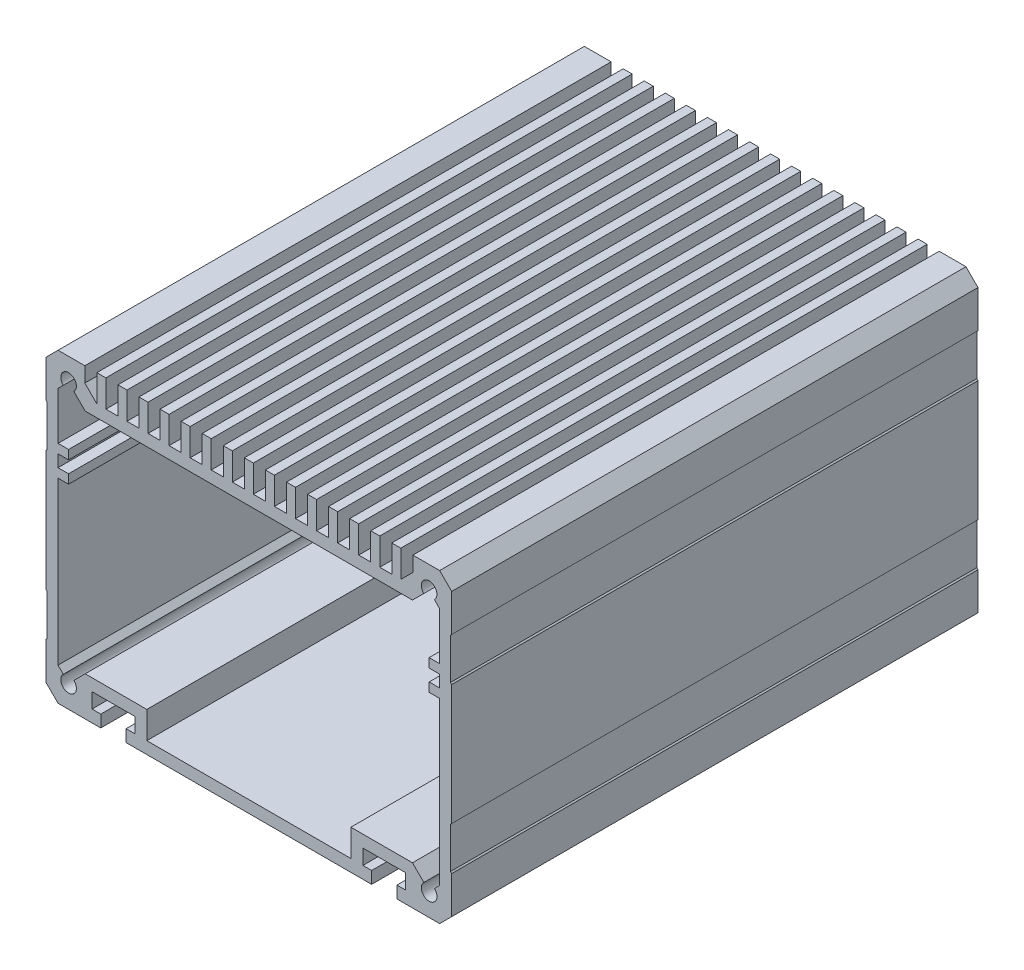
from build123d import *

# Parameters (mm, degrees)
BOSS_EXTRUDE1_DEPTH = 87.4395


with BuildPart() as part:
    # Sketch1 → Boss-Extrude1 (new body)
    with BuildSketch(Plane.XY.offset(12.5605)):
        Polygon((-54.188249545, 1.80757214), (-54.188249545, -0.19242786), (-13.388249545, -0.19242786), (-13.388249545, 1.80757214), (-14.838249545, 1.80757214), (-14.838249545, 4.30757214), (-7.738249545, 4.30757214), (-7.738249545, 1.80757214), (-9.188249545, 1.80757214), (-9.188249545, -0.19242786), (-2.088249216, -0.19242786), (-0.088249545, 1.807571812), (-0.088249545, 8.007572024), (-0.288249545, 8.207572024), (-0.288249545, 15.00757214), (-0.088249545, 15.20757214), (-0.088249545, 35.20757214), (-0.288249545, 35.40757214), (-0.288249545, 42.207572024), (-0.088249545, 42.407572024), (-0.088249545, 48.607572237), (-2.088249448, 50.60757214), (-6.538249545, 50.60757214), (-6.538249545, 48.10757214), (-8.538249545, 46.10757214), (-8.538249545, 50.60757214), (-10.038249545, 50.60757214), (-10.038249545, 46.10757214), (-12.038249545, 46.10757214), (-12.038249545, 50.60757214), (-13.538249545, 50.60757214), (-13.538249545, 46.10757214), (-15.538249545, 46.10757214), (-15.538249545, 50.60757214), (-17.038249545, 50.60757214), (-17.038249545, 46.10757214), (-19.038249545, 46.10757214), (-19.038249545, 50.60757214), (-20.538249545, 50.60757214), (-20.538249545, 46.10757214), (-22.538249545, 46.10757214), (-22.538249545, 50.60757214), (-24.038249545, 50.60757214), (-24.038249545, 46.10757214), (-26.038249545, 46.10757214), (-26.038249545, 50.60757214), (-27.538249545, 50.60757214), (-27.538249545, 46.10757214), (-29.538249545, 46.10757214), (-29.538249545, 50.60757214), (-31.038249545, 50.60757214), (-31.038249545, 46.10757214), (-33.038249545, 46.10757214), (-33.038249545, 50.60757214), (-34.538249545, 50.60757214), (-34.538249545, 46.10757214), (-36.538249545, 46.10757214), (-36.538249545, 50.60757214), (-38.038249545, 50.60757214), (-38.038249545, 46.10757214), (-40.038249545, 46.10757214), (-40.038249545, 50.60757214), (-41.538249545, 50.60757214), (-41.538249545, 46.10757214), (-43.538249545, 46.10757214), (-43.538249545, 50.60757214), (-45.038249545, 50.60757214), (-45.038249545, 46.10757214), (-47.038249545, 46.10757214), (-47.038249545, 50.60757214), (-48.538249545, 50.60757214), (-48.538249545, 46.10757214), (-50.538249545, 46.10757214), (-50.538249545, 50.60757214), (-52.038249545, 50.60757214), (-52.038249545, 46.10757214), (-54.038249545, 46.10757214), (-54.038249545, 50.60757214), (-55.538249545, 50.60757214), (-55.538249545, 46.10757214), (-57.538249545, 46.10757214), (-57.538249545, 50.60757214), (-59.038249545, 50.60757214), (-59.038249545, 46.10757214), (-61.038249545, 48.10757214), (-61.038249545, 50.60757214), (-65.488249642, 50.60757214), (-67.488249545, 48.607572237), (-67.488249545, 42.407572024), (-67.288249545, 42.207572024), (-67.288249545, 35.40757214), (-67.488249545, 35.20757214), (-67.488249545, 15.20757214), (-67.288249545, 15.00757214), (-67.288249545, 8.207572024), (-67.488249545, 8.007572024), (-67.488249545, 1.807571812), (-65.488249874, -0.19242786), (-58.388249545, -0.19242786), (-58.388249545, 1.80757214), (-59.838249545, 1.80757214), (-59.838249545, 4.30757214), (-52.738249545, 4.30757214), (-52.738249545, 1.80757214), align=None)
        with BuildLine():
            Line((-2.088249545, 32.20757214), (-2.088249545, 5.294016009))
            Line((-2.088249545, 5.294016009), (-2.963249358, 4.419016196))
            ThreePointArc((-2.963249358, 4.419016196), (-3.838249708, 2.15757214), (-4.713249491, 4.419016416))
            Line((-4.713249491, 4.419016416), (-6.601805216, 6.30757214))
            Line((-6.601805216, 6.30757214), (-16.838249545, 6.30757214))
            Line((-16.838249545, 6.30757214), (-16.838249545, 1.807572024))
            Line((-16.838249545, 1.807572024), (-50.738249545, 1.807572024))
            Line((-50.738249545, 1.807572024), (-50.738249545, 6.30757214))
            Line((-50.738249545, 6.30757214), (-60.974693874, 6.30757214))
            Line((-60.974693874, 6.30757214), (-62.863249599, 4.419016416))
            ThreePointArc((-62.863249599, 4.419016416), (-63.738249382, 2.15757214), (-64.613249732, 4.419016196))
            Line((-64.613249732, 4.419016196), (-65.488249545, 5.294016009))
            Line((-65.488249545, 5.294016009), (-65.488249545, 32.20757214))
            Line((-65.488249545, 32.20757214), (-63.738249545, 32.20757214))
            Line((-63.738249545, 32.20757214), (-63.738249545, 33.70757214))
            Line((-63.738249545, 33.70757214), (-65.488249545, 33.70757214))
            Line((-65.488249545, 33.70757214), (-65.488249545, 35.70757214))
            Line((-65.488249545, 35.70757214), (-63.738249545, 35.70757214))
            Line((-63.738249545, 35.70757214), (-63.738249545, 37.20757214))
            Line((-63.738249545, 37.20757214), (-65.488249545, 37.20757214))
            Line((-65.488249545, 37.20757214), (-65.488249545, 45.121128024))
            Line((-65.488249545, 45.121128024), (-64.613249603, 45.996127967))
            ThreePointArc((-64.613249603, 45.996127967), (-63.738249551, 48.25757214), (-62.863249479, 45.996127974))
            Line((-62.863249479, 45.996127974), (-60.974693645, 44.10757214))
            Line((-60.974693645, 44.10757214), (-6.601805445, 44.10757214))
            Line((-6.601805445, 44.10757214), (-4.713249611, 45.996127974))
            ThreePointArc((-4.713249611, 45.996127974), (-3.838249539, 48.25757214), (-2.963249487, 45.996127967))
            Line((-2.963249487, 45.996127967), (-2.088249545, 45.121128024))
            Line((-2.088249545, 45.121128024), (-2.088249545, 37.20757214))
            Line((-2.088249545, 37.20757214), (-3.838249545, 37.20757214))
            Line((-3.838249545, 37.20757214), (-3.838249545, 35.70757214))
            Line((-3.838249545, 35.70757214), (-2.088249545, 35.70757214))
            Line((-2.088249545, 35.70757214), (-2.088249545, 33.70757214))
            Line((-2.088249545, 33.70757214), (-3.838249545, 33.70757214))
            Line((-3.838249545, 33.70757214), (-3.838249545, 32.20757214))
            Line((-3.838249545, 32.20757214), (-2.088249545, 32.20757214))
        make_face(mode=Mode.SUBTRACT)
    extrude(amount=BOSS_EXTRUDE1_DEPTH)


solid = part.part
